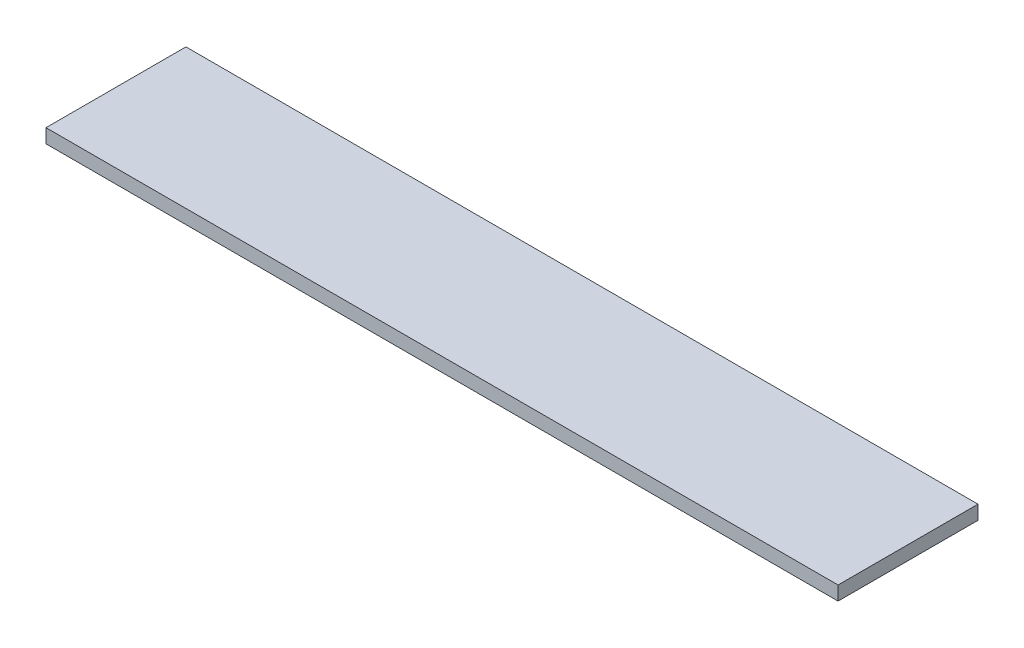
from build123d import *

# Parameters (mm, degrees)
ESQUISSE1_W      = 566
ESQUISSE1_H      = 100
EXTRUSION1_DEPTH = 10


with BuildPart() as part:
    # Esquisse1 → Extrusion1 (new body)
    with BuildSketch(Plane(origin=(0, 0, 0), x_dir=(1, 0, 0), z_dir=(0, 1, 0))):
        with Locations((283, 50)):
            Rectangle(ESQUISSE1_W, ESQUISSE1_H)
    extrude(amount=EXTRUSION1_DEPTH)


solid = part.part
